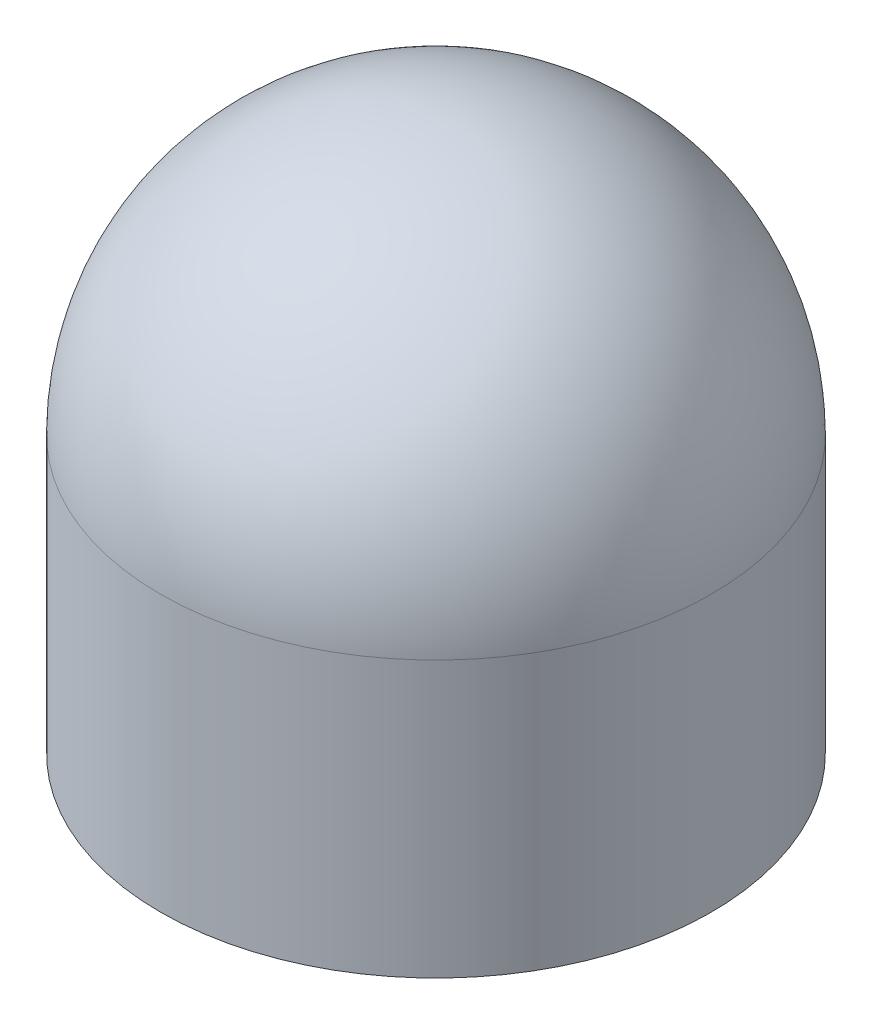
from build123d import *

# Parameters (mm, degrees)
SKETCH1_R           = 3
BOSS_EXTRUDE1_DEPTH = 3


with BuildPart() as part:
    # Sketch1 → Boss-Extrude1 (new body)
    with BuildSketch(Plane(origin=(0, 0, 0), x_dir=(1, 0, 0), z_dir=(0, 1, 0))):
        with Locations((-37.190505929, 7.698671609)):
            Circle(SKETCH1_R)
    extrude(amount=BOSS_EXTRUDE1_DEPTH)

    # Sketch2 → Revolve1 (revolve)
    with BuildSketch(Plane(origin=(0, 3, 0), x_dir=(1, 0, 0), z_dir=(0, 1, 0))):
        with BuildLine():
            Line((-37.190505929, 10.698671609), (-37.190505929, 4.698671609))
            ThreePointArc((-37.190505929, 4.698671609), (-40.190505929, 7.698671609), (-37.190505929, 10.698671609))
        make_face()
    revolve(axis=Axis((-37.190505929, 3, -10.698671609), (0, 0, 1)))


solid = part.part
